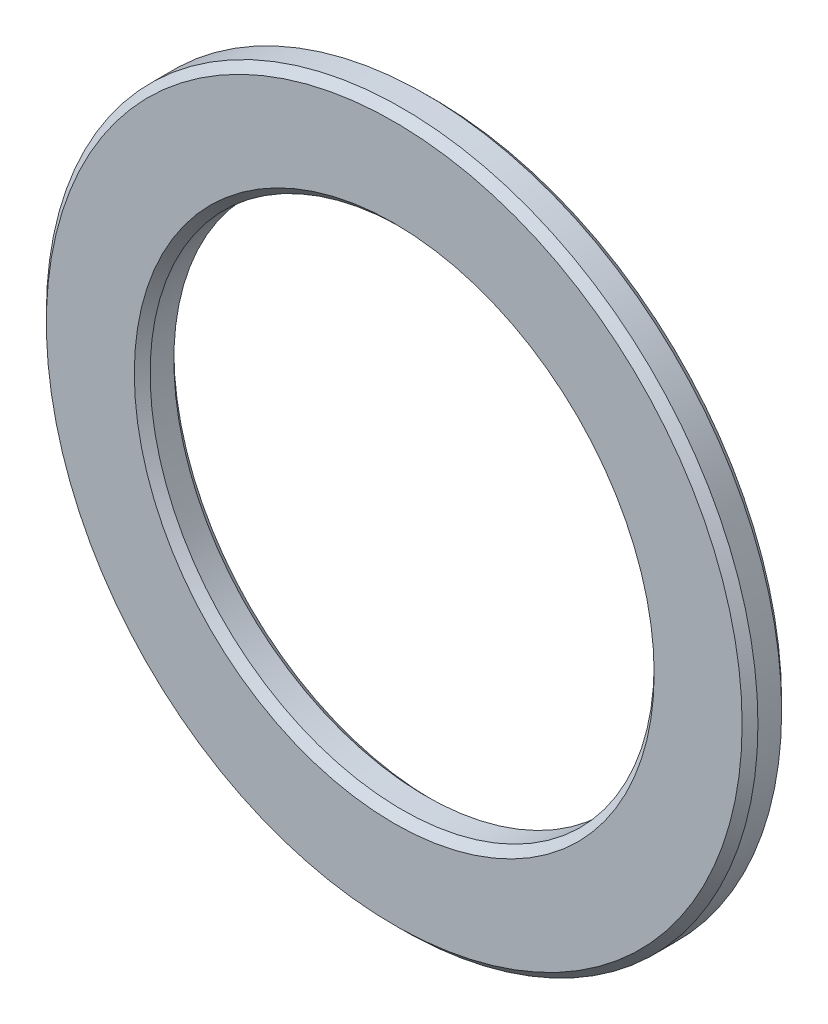
from build123d import *

# Parameters (mm, degrees)
SKETCH1_R           = 18
SKETCH1_R_2         = 12.75
BOSS_EXTRUDE1_DEPTH = 1
CHAMFER1_SIZE       = 0.4


with BuildPart() as part:
    # Sketch1 → Boss-Extrude1 (new body, symmetric)
    with BuildSketch(Plane.XY):
        Circle(SKETCH1_R)
        Circle(SKETCH1_R_2, mode=Mode.SUBTRACT)
    extrude(amount=BOSS_EXTRUDE1_DEPTH, both=True)

    # Chamfer1
    chamfer1_edges = [part.edges().sort_by_distance(p)[0] for p in [
        (-18, 0, -1),
        (-18, 0, 1),
        (-12.75, 0, -1),
        (-12.75, 0, 1),
    ]]
    chamfer(chamfer1_edges, length=CHAMFER1_SIZE)


solid = part.part
